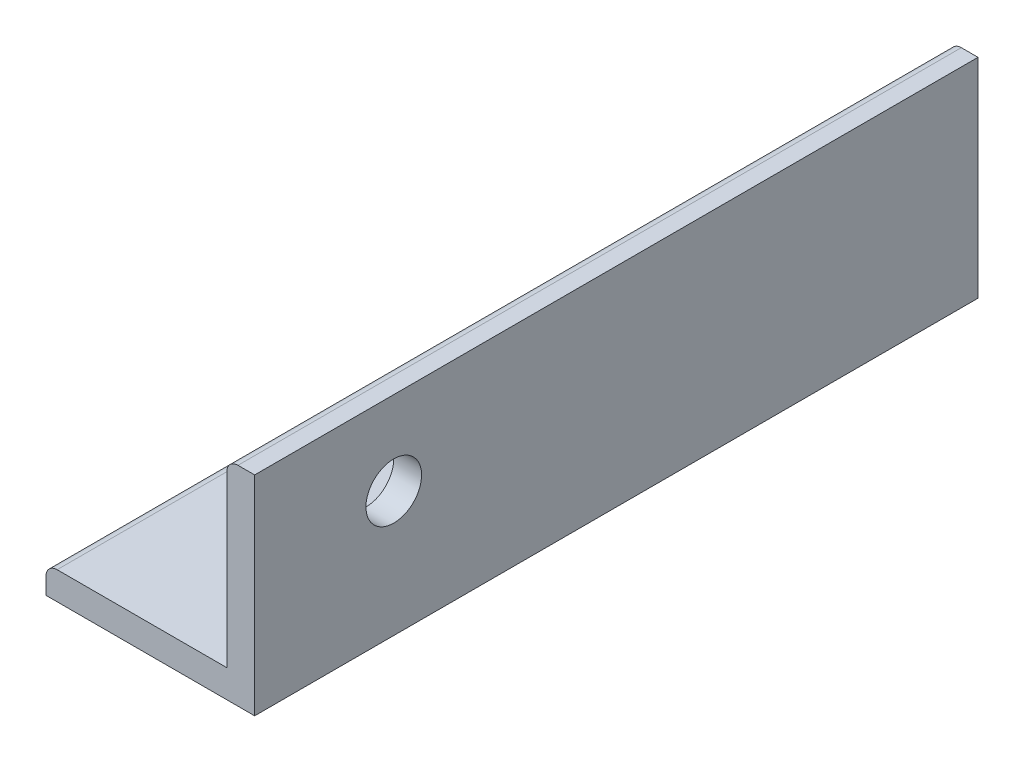
from build123d import *

# Parameters (mm, degrees)
EXTRUDE_1_DEPTH     = 52
FILLET_1_R          = 0.8
SKETCH_3_R          = 2
CUT_EXTRUDE_2_DEPTH = 2


with BuildPart() as part:
    # 草图1 → 凸台-拉伸1 (new body)
    with BuildSketch(Plane.XY):
        Polygon((0, 0), (0, 15), (-2, 15), (-2, 2), (-15, 2), (-15, 0), align=None)
    extrude(amount=EXTRUDE_1_DEPTH)

    # 圆角1
    fillet_1_edges = [part.edges().sort_by_distance(p)[0] for p in [
        (-15, 2, 26),
        (-2, 15, 26),
    ]]
    fillet(fillet_1_edges, radius=FILLET_1_R)

    # 草图3 → 切除-拉伸2 (cut)
    with BuildSketch(Plane.ZY.offset(2)):
        with Locations((42, 9)):
            Circle(SKETCH_3_R)
    extrude(amount=-CUT_EXTRUDE_2_DEPTH, mode=Mode.SUBTRACT)


solid = part.part
